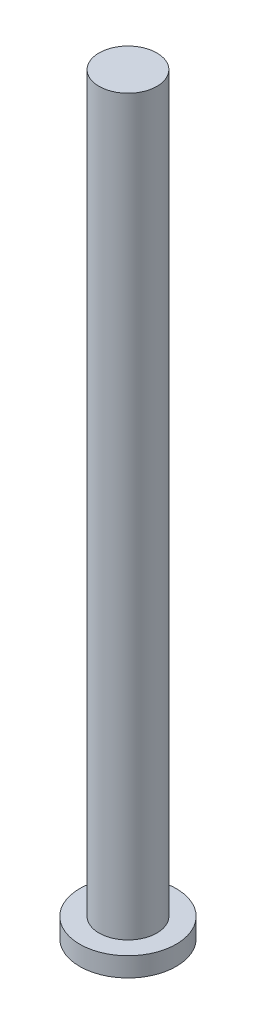
from build123d import *

# Parameters (mm, degrees)
SKETCH1_R           = 2.5
BOSS_EXTRUDE1_DEPTH = 1
SKETCH2_R           = 1.5
BOSS_EXTRUDE2_DEPTH = 38


with BuildPart() as part:
    # Sketch1 → Boss-Extrude1 (new body)
    with BuildSketch(Plane(origin=(0, 0, 0), x_dir=(1, 0, 0), z_dir=(0, 1, 0))):
        Circle(SKETCH1_R)
    extrude(amount=BOSS_EXTRUDE1_DEPTH)

    # Sketch2 → Boss-Extrude2 (add)
    with BuildSketch(Plane(origin=(0, 1, 0), x_dir=(1, 0, 0), z_dir=(0, 1, 0))):
        Circle(SKETCH2_R)
    extrude(amount=BOSS_EXTRUDE2_DEPTH)


solid = part.part
